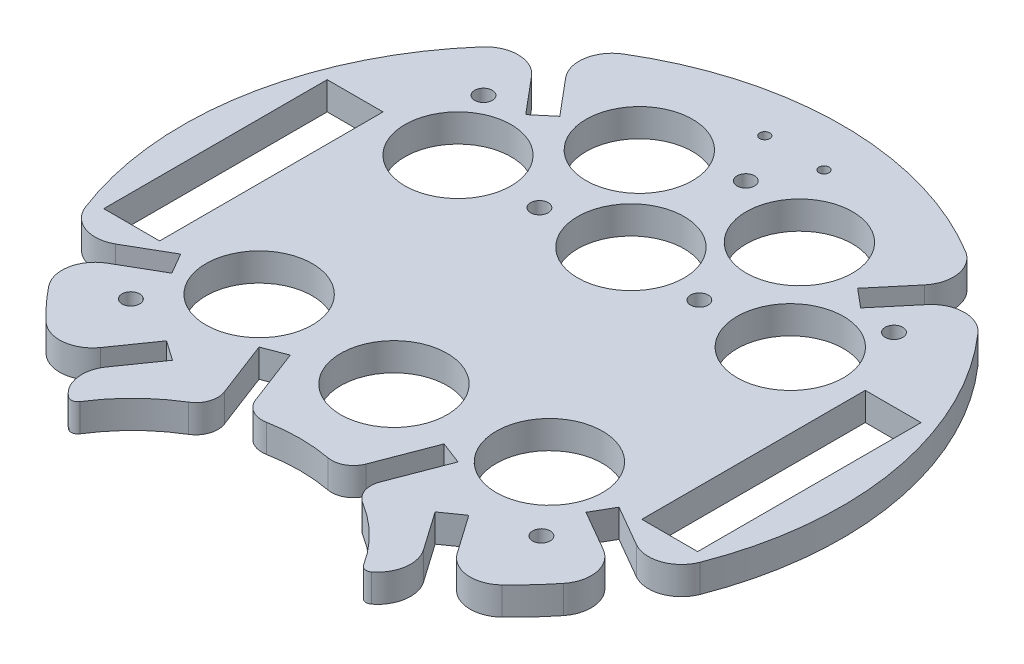
from build123d import *

# Parameters (mm, degrees)
SKETCH1_R           = 2
SKETCH1_W           = 12.7
SKETCH1_H           = 50.8
SKETCH1_R_2         = 12.095
SKETCH1_R_3         = 12.075
SKETCH1_R_4         = 1.143
BOSS_EXTRUDE1_DEPTH = 6.35


with BuildPart() as part:
    # Sketch1 → Boss-Extrude1 (new body)
    with BuildSketch(Plane(origin=(0, 0, 0), x_dir=(1, 0, 0), z_dir=(0, 1, 0))):
        with BuildLine():
            Line((-40.520093651, -53.074212293), (-34.358059191, -44.273915061))
            Line((-34.358059191, -44.273915061), (-29.852722948, -47.428585461))
            Line((-29.852722948, -47.428585461), (-36.014757408, -56.228882693))
            ThreePointArc((-36.014757408, -56.228882693), (-37.282182463, -61.682274385), (-34.419720881, -66.493943628))
            ThreePointArc((-34.419720881, -66.493943628), (-33.243515234, -66.777434912), (-32.240681933, -66.10056535))
            ThreePointArc((-32.240681933, -66.10056535), (-26.728650164, -59.250774979), (-19.793246149, -53.846860332))
            ThreePointArc((-19.793246149, -53.846860332), (-17.659799789, -51.192486841), (-17.721018114, -47.787557426))
            Line((-17.721018114, -47.787557426), (-22.618223277, -34.99005566))
            Line((-22.618223277, -34.99005566), (-17.481479686, -33.024383946))
            Line((-17.481479686, -33.024383946), (-12.584274523, -45.821885712))
            ThreePointArc((-12.584274523, -45.821885712), (-10.356790186, -48.397852623), (-6.996351286, -48.949887413))
            ThreePointArc((-6.996351286, -48.949887413), (0, -48.302004425), (6.996351286, -48.949887413))
            ThreePointArc((6.996351286, -48.949887413), (10.356790186, -48.397852623), (12.584274523, -45.821885712))
            Line((12.584274523, -45.821885712), (17.481479686, -33.024383946))
            Line((17.481479686, -33.024383946), (22.618223277, -34.99005566))
            Line((22.618223277, -34.99005566), (17.721018114, -47.787557426))
            ThreePointArc((17.721018114, -47.787557426), (17.659799789, -51.192486841), (19.793246149, -53.846860332))
            ThreePointArc((19.793246149, -53.846860332), (26.728650164, -59.250774979), (32.240681933, -66.10056535))
            ThreePointArc((32.240681933, -66.10056535), (33.243515234, -66.777434912), (34.419720881, -66.493943628))
            ThreePointArc((34.419720881, -66.493943628), (37.282182463, -61.682274385), (36.014757408, -56.228882693))
            Line((36.014757408, -56.228882693), (29.852722948, -47.428585461))
            Line((29.852722948, -47.428585461), (34.358059191, -44.273915061))
            Line((34.358059191, -44.273915061), (40.520093651, -53.074212293))
            ThreePointArc((40.520093651, -53.074212293), (45.927580176, -56.23617342), (51.848593315, -54.191543356))
            ThreePointArc((51.848593315, -54.191543356), (55.295899374, -50.669157408), (58.504414423, -46.927960674))
            ThreePointArc((58.504414423, -46.927960674), (60.030901261, -40.882046302), (56.458030011, -35.771485305))
            Line((56.458030011, -35.771485305), (56.349654942, -35.70891493))
            Line((56.349654942, -35.70891493), (47.078155187, -30.35601205))
            Line((47.078155187, -30.35601205), (49.828155187, -25.59287233))
            Line((49.828155187, -25.59287233), (59.099654942, -30.945775209))
            Line((59.099654942, -30.945775209), (59.208030011, -31.008345585))
            ThreePointArc((59.208030011, -31.008345585), (65.420341286, -31.547262353), (69.893013303, -27.202328787))
            ThreePointArc((69.893013303, -27.202328787), (73.860606951, 13.023468848), (56.374397975, 49.466425512))
            ThreePointArc((56.374397975, 49.466425512), (50.654117331, 52.01932544), (44.991624855, 49.340690033))
            Line((44.991624855, 49.340690033), (38.069871869, 41.091666046))
            Line((38.069871869, 41.091666046), (33.856627432, 44.626997899))
            Line((33.856627432, 44.626997899), (40.778380417, 52.876021886))
            ThreePointArc((40.778380417, 52.876021886), (42.433039833, 58.917628536), (38.925607882, 64.107698843))
            ThreePointArc((38.925607882, 64.107698843), (0, 75), (-38.925607882, 64.107698843))
            ThreePointArc((-38.925607882, 64.107698843), (-42.433039833, 58.917628536), (-40.778380417, 52.876021886))
            Line((-40.778380417, 52.876021886), (-33.856627432, 44.626997899))
            Line((-33.856627432, 44.626997899), (-38.069871869, 41.091666046))
            Line((-38.069871869, 41.091666046), (-44.991624855, 49.340690033))
            ThreePointArc((-44.991624855, 49.340690033), (-50.654117331, 52.01932544), (-56.374397975, 49.466425512))
            ThreePointArc((-56.374397975, 49.466425512), (-73.860606951, 13.023468848), (-69.893013303, -27.202328787))
            ThreePointArc((-69.893013303, -27.202328787), (-65.420341286, -31.547262353), (-59.208030011, -31.008345585))
            Line((-59.208030011, -31.008345585), (-59.099654942, -30.945775209))
            Line((-59.099654942, -30.945775209), (-49.828155187, -25.59287233))
            Line((-49.828155187, -25.59287233), (-47.078155187, -30.35601205))
            Line((-47.078155187, -30.35601205), (-56.349654942, -35.70891493))
            Line((-56.349654942, -35.70891493), (-56.458030011, -35.771485305))
            ThreePointArc((-56.458030011, -35.771485305), (-60.030901261, -40.882046302), (-58.504414423, -46.927960674))
            ThreePointArc((-58.504414423, -46.927960674), (-55.295899374, -50.669157408), (-51.848593315, -54.191543356))
            ThreePointArc((-51.848593315, -54.191543356), (-45.927580176, -56.23617342), (-40.520093651, -53.074212293))
        make_face()
        with Locations((-46.663733983, -40.081231883)):
            Circle(SKETCH1_R, mode=Mode.SUBTRACT)
        with Locations((-61.164123727, 0)):
            Rectangle(SKETCH1_W, SKETCH1_H, mode=Mode.SUBTRACT)
        with Locations((-32.995567884, -24.592872328)):
            Circle(SKETCH1_R_2, mode=Mode.SUBTRACT)
        with Locations((46.663733983, -40.081231883)):
            Circle(SKETCH1_R, mode=Mode.SUBTRACT)
        with Locations((0, -26.93833729)):
            Circle(SKETCH1_R_2, mode=Mode.SUBTRACT)
        with Locations((32.995567884, -24.592872328)):
            Circle(SKETCH1_R_2, mode=Mode.SUBTRACT)
        with Locations((61.164123727, 0)):
            Rectangle(SKETCH1_W, SKETCH1_H, mode=Mode.SUBTRACT)
        with Locations((-37.772386793, 25.4)):
            Circle(SKETCH1_R_3, mode=Mode.SUBTRACT)
        with Locations((-18.178952795, 24.310551096)):
            Circle(SKETCH1_R, mode=Mode.SUBTRACT)
        with Locations((-46.663733983, 40.081231883)):
            Circle(SKETCH1_R, mode=Mode.SUBTRACT)
        with Locations((-18.1962694, 47.045805056)):
            Circle(SKETCH1_R_2, mode=Mode.SUBTRACT)
        with Locations((-6.731, 64.107698843)):
            Circle(SKETCH1_R_4, mode=Mode.SUBTRACT)
        with Locations((0, 26.93833729)):
            Circle(SKETCH1_R_2, mode=Mode.SUBTRACT)
        with Locations((18.178952795, 24.310551096)):
            Circle(SKETCH1_R, mode=Mode.SUBTRACT)
        with Locations((37.772386793, 25.4)):
            Circle(SKETCH1_R_2, mode=Mode.SUBTRACT)
        with Locations((18.1962694, 47.045805056)):
            Circle(SKETCH1_R_2, mode=Mode.SUBTRACT)
        with Locations((0, 53.061187965)):
            Circle(SKETCH1_R, mode=Mode.SUBTRACT)
        with Locations((6.731, 64.107698843)):
            Circle(SKETCH1_R_4, mode=Mode.SUBTRACT)
        with Locations((46.663733983, 40.081231883)):
            Circle(SKETCH1_R, mode=Mode.SUBTRACT)
    extrude(amount=BOSS_EXTRUDE1_DEPTH)


solid = part.part
